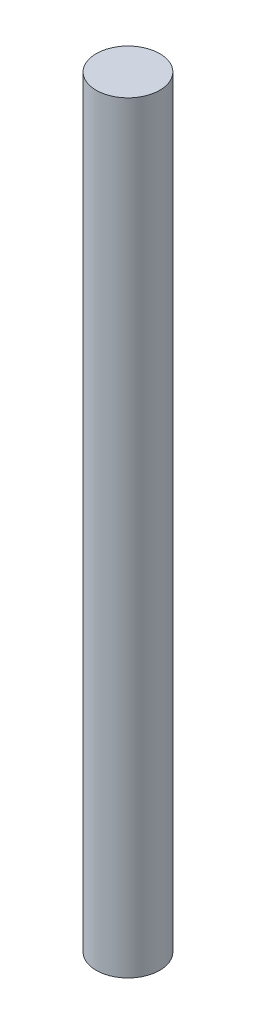
from build123d import *

# Parameters (mm, degrees)
SKETCH2_R           = 30
BOSS_EXTRUDE1_DEPTH = 720


with BuildPart() as part:
    # Sketch2 → Boss-Extrude1 (new body)
    with BuildSketch(Plane(origin=(0, 0, 0), x_dir=(1, 0, 0), z_dir=(0, 1, 0))):
        Circle(SKETCH2_R)
    extrude(amount=BOSS_EXTRUDE1_DEPTH)


solid = part.part
